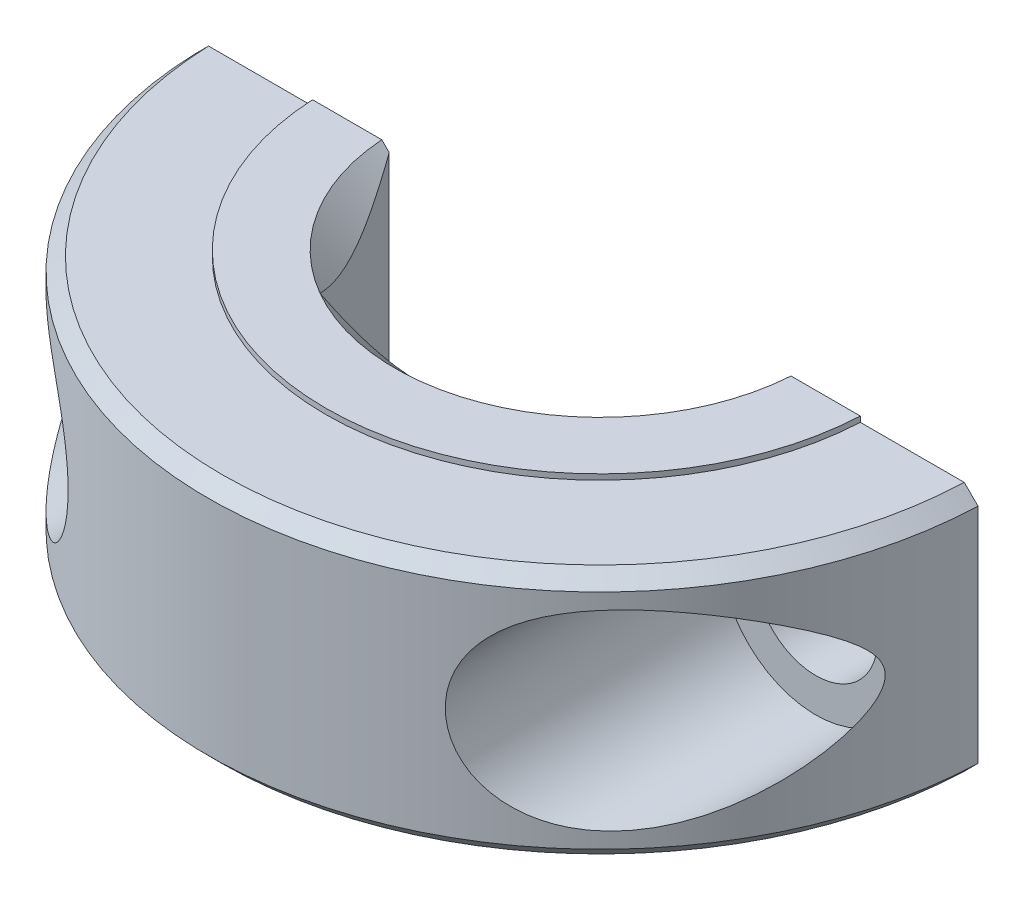
from build123d import *

# Parameters (mm, degrees)
BOSS_EXTRUDE1_DEPTH                                 = 9.525
CUT_EXTRUDE7_DEPTH                                  = 0.2
CUT_EXTRUDE8_DEPTH                                  = 0.2
CBORE_FOR_8_BINDING_HEAD_MACHINE_SCREW4_D           = 4.4958
CBORE_FOR_8_BINDING_HEAD_MACHINE_SCREW4_DEPTH       = 12.024265282
CBORE_FOR_8_BINDING_HEAD_MACHINE_SCREW4_CBORE_D     = 6.985
CBORE_FOR_8_BINDING_HEAD_MACHINE_SCREW4_CBORE_DEPTH = 10.024265282
CHAMFER4_SIZE                                       = 0.5


with BuildPart() as part:
    # Sketch32 → Boss-Extrude1 (new body)
    with BuildSketch(Plane(origin=(0, 4.7625, 0), x_dir=(1, 0, 0), z_dir=(0, 1, 0))):
        with BuildLine():
            Line((14.278748413, -0.5), (7.190320252, -0.5))
            Line((7.190320252, -0.5), (3.739497694, -6.477))
            Line((3.739497694, -6.477), (-3.739497694, -6.477))
            Line((-3.739497694, -6.477), (-7.190320252, -0.5))
            Line((-7.190320252, -0.5), (-14.278748413, -0.5))
            ThreePointArc((-14.278748413, -0.5), (0, -14.2875), (14.278748413, -0.5))
        make_face()
    extrude(amount=-BOSS_EXTRUDE1_DEPTH)

    # Sketch37 → Cut-Revolve4 (revolve, cut)
    with BuildSketch(Plane(origin=(0, 0, 0), x_dir=(-0.99776158, 0, -0.06687174), z_dir=(0.06687174, 0, -0.99776158))):
        Polygon((0, -4.7625), (0, -3.7625), (-6.477, -3.7625), (-7.477, -4.7625), align=None)
    revolve(axis=Axis((0, -4.7625, 0), (0, 1, 0)), mode=Mode.SUBTRACT)

    # Sketch43 → Cut-Revolve5 (revolve, cut)
    with BuildSketch(Plane(origin=(0, 0, 0), x_dir=(-0.99776158, 0, 0.06687174), z_dir=(-0.06687174, 0, -0.99776158))):
        Polygon((0, 4.7625), (0, 3.7625), (6.477, 3.7625), (7.477, 4.7625), align=None)
    revolve(axis=Axis((0, 4.7625, 0), (0, -1, 0)), mode=Mode.SUBTRACT)

    # Sketch48 → Cut-Extrude7 (cut)
    with BuildSketch(Plane(origin=(0, 4.7625, 0), x_dir=(1, 0, 0), z_dir=(0, 1, 0))):
        with BuildLine():
            Line((14.278748413, -0.5), (9.987492178, -0.5))
            ThreePointArc((9.987492178, -0.5), (0, -10), (-9.987492178, -0.5))
            Line((-9.987492178, -0.5), (-14.278748413, -0.5))
            ThreePointArc((-14.278748413, -0.5), (0, -14.2875), (14.278748413, -0.5))
        make_face()
    extrude(amount=-CUT_EXTRUDE7_DEPTH, mode=Mode.SUBTRACT)

    # Sketch49 → Cut-Extrude8 (cut)
    with BuildSketch(Plane.XZ.offset(4.7625)):
        with BuildLine():
            Line((9.987492178, 0.5), (14.278748413, 0.5))
            ThreePointArc((14.278748413, 0.5), (0, 14.2875), (-14.278748413, 0.5))
            Line((-14.278748413, 0.5), (-9.987492178, 0.5))
            ThreePointArc((-9.987492178, 0.5), (0, 10), (9.987492178, 0.5))
        make_face()
    extrude(amount=-CUT_EXTRUDE8_DEPTH, mode=Mode.SUBTRACT)

    # CBORE for #8 Binding Head Machine Screw4
    with Locations(Plane.XY.offset(12.524265282)):
        with Locations((-10.368210259, 0), (10.368210259, 0)):
            CounterBoreHole(CBORE_FOR_8_BINDING_HEAD_MACHINE_SCREW4_D / 2, CBORE_FOR_8_BINDING_HEAD_MACHINE_SCREW4_CBORE_D / 2, CBORE_FOR_8_BINDING_HEAD_MACHINE_SCREW4_CBORE_DEPTH, depth=CBORE_FOR_8_BINDING_HEAD_MACHINE_SCREW4_DEPTH)

    # Chamfer4
    chamfer4_edges = [part.edges().sort_by_distance(p)[0] for p in [
        (0, 4.5625, 14.2875),
        (0, -4.5625, 14.2875),
    ]]
    chamfer(chamfer4_edges, length=CHAMFER4_SIZE)


solid = part.part
